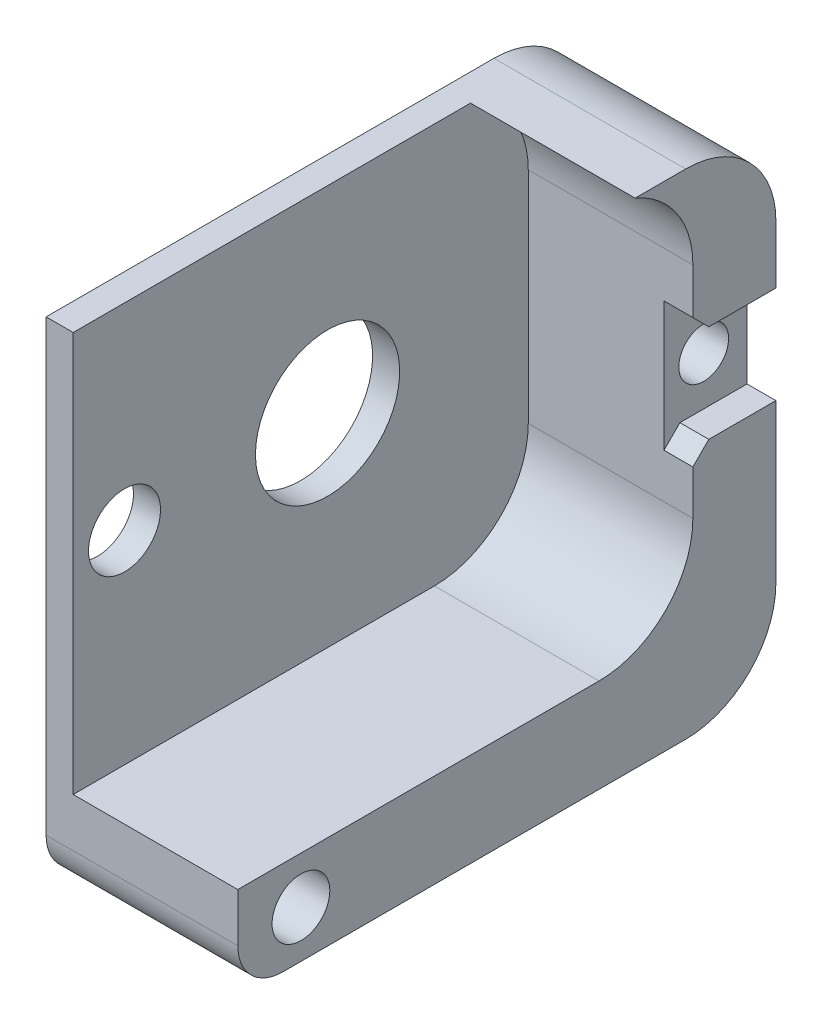
from build123d import *

# Parameters (mm, degrees)
BOSS_EXTRUDE1_START = -7.320002
SKETCH1_R           = 1.38
SKETCH1_R_2         = 1.6
BOSS_EXTRUDE1_DEPTH = 7.520002
BOSS_EXTRUDE2_START = -8.920002
SKETCH1_3_R         = 1.6
BOSS_EXTRUDE2_DEPTH = 1.6
BOSS_EXTRUDE3_START = 0.2
SKETCH1_4_R         = 1.6
SKETCH1_4_R_2       = 1.38
SKETCH1_4_R_3       = 3.995
SKETCH1_4_R_4       = 1.995
BOSS_EXTRUDE3_DEPTH = 1.5


with BuildPart() as part:
    # Sketch1 → Boss-Extrude1 (new body)
    with BuildSketch(Plane.ZY.offset(18.486711134).offset(BOSS_EXTRUDE1_START)):
        with BuildLine():
            ThreePointArc((-12.870344381, -12.708128144), (-11.997005912, -9.823687124), (-9.670344381, -7.908128144))
            Line((-9.670344381, -7.908128144), (-12.470344381, -7.908128144))
            ThreePointArc((-12.470344381, -7.908128144), (-16.005878287, -9.372594238), (-17.470344381, -12.908128144))
            Line((-17.470344381, -12.908128144), (-17.470344381, -30.276049303))
            ThreePointArc((-17.470344381, -30.276049303), (-16.005878287, -33.811583208), (-12.470344381, -35.276049303))
            Line((-12.470344381, -35.276049303), (9.844655619, -35.276049303))
            ThreePointArc((9.844655619, -35.276049303), (11.612422572, -34.543816256), (12.344655619, -32.776049303))
            Line((12.344655619, -32.776049303), (12.344655619, -30.076049303))
            Line((12.344655619, -30.076049303), (-7.670344381, -30.076049303))
            ThreePointArc((-7.670344381, -30.076049303), (-11.347299643, -28.553004565), (-12.870344381, -24.876049303))
            Line((-12.870344381, -24.876049303), (-12.870344381, -12.708128144))
        make_face()
        with Locations((-15.070344381, -18.823128144)):
            Circle(SKETCH1_R, mode=Mode.SUBTRACT)
        with Locations((8.844655619, -32.676049303)):
            Circle(SKETCH1_R_2, mode=Mode.SUBTRACT)
    extrude(amount=BOSS_EXTRUDE1_DEPTH)

    # Sketch1_3 → Boss-Extrude2 (add)
    with BuildSketch(Plane.ZY.offset(18.486711134).offset(BOSS_EXTRUDE2_START)):
        with BuildLine():
            ThreePointArc((-12.870344381, -12.708128144), (-11.997005912, -9.823687124), (-9.670344381, -7.908128144))
            Line((-9.670344381, -7.908128144), (-12.470344381, -7.908128144))
            ThreePointArc((-12.470344381, -7.908128144), (-16.005878287, -9.372594238), (-17.470344381, -12.908128144))
            Line((-17.470344381, -12.908128144), (-17.470344381, -16.123128144))
            Line((-17.470344381, -16.123128144), (-13.753187094, -16.123128144))
            Line((-13.753187094, -16.123128144), (-12.870344381, -15.240285432))
            Line((-12.870344381, -15.240285432), (-12.870344381, -12.708128144))
        make_face()
        with BuildLine():
            Line((12.344655619, -32.776049303), (12.344655619, -30.076049303))
            Line((12.344655619, -30.076049303), (-7.670344381, -30.076049303))
            ThreePointArc((-7.670344381, -30.076049303), (-11.347299643, -28.553004565), (-12.870344381, -24.876049303))
            Line((-12.870344381, -24.876049303), (-12.870344381, -22.405970857))
            Line((-12.870344381, -22.405970857), (-13.753187094, -21.523128144))
            Line((-13.753187094, -21.523128144), (-17.470344381, -21.523128144))
            Line((-17.470344381, -21.523128144), (-17.470344381, -30.276049303))
            ThreePointArc((-17.470344381, -30.276049303), (-16.005878287, -33.811583208), (-12.470344381, -35.276049303))
            Line((-12.470344381, -35.276049303), (9.844655619, -35.276049303))
            ThreePointArc((9.844655619, -35.276049303), (11.612422572, -34.543816256), (12.344655619, -32.776049303))
        make_face()
        with Locations((8.844655619, -32.676049303)):
            Circle(SKETCH1_3_R, mode=Mode.SUBTRACT)
    extrude(amount=BOSS_EXTRUDE2_DEPTH)

    # Sketch1_4 → Boss-Extrude3 (add)
    with BuildSketch(Plane.ZY.offset(18.486711134).offset(BOSS_EXTRUDE3_START)):
        with BuildLine():
            ThreePointArc((-12.870344381, -24.876049303), (-11.347299643, -28.553004565), (-7.670344381, -30.076049303))
            Line((-7.670344381, -30.076049303), (12.344655619, -30.076049303))
            Line((12.344655619, -30.076049303), (12.344655619, -32.776049303))
            ThreePointArc((12.344655619, -32.776049303), (11.612422572, -34.543816256), (9.844655619, -35.276049303))
            Line((9.844655619, -35.276049303), (-12.470344381, -35.276049303))
            ThreePointArc((-12.470344381, -35.276049303), (-16.005878287, -33.811583208), (-17.470344381, -30.276049303))
            Line((-17.470344381, -30.276049303), (-17.470344381, -21.523128144))
            Line((-17.470344381, -21.523128144), (-13.753187094, -21.523128144))
            Line((-13.753187094, -21.523128144), (-12.870344381, -22.405970857))
            Line((-12.870344381, -22.405970857), (-12.870344381, -24.876049303))
        make_face()
        with Locations((8.844655619, -32.676049303)):
            Circle(SKETCH1_4_R, mode=Mode.SUBTRACT)
        with BuildLine():
            ThreePointArc((-9.670344381, -7.908128144), (-11.997005912, -9.823687124), (-12.870344381, -12.708128144))
            Line((-12.870344381, -12.708128144), (-12.870344381, -15.240285432))
            Line((-12.870344381, -15.240285432), (-13.753187094, -16.123128144))
            Line((-13.753187094, -16.123128144), (-17.470344381, -16.123128144))
            Line((-17.470344381, -16.123128144), (-17.470344381, -12.908128144))
            ThreePointArc((-17.470344381, -12.908128144), (-16.005878287, -9.372594238), (-12.470344381, -7.908128144))
            Line((-12.470344381, -7.908128144), (-9.670344381, -7.908128144))
        make_face()
        Polygon((-12.870344381, -22.405970857), (-12.870344381, -15.240285432), (-13.753187094, -16.123128144), (-17.470344381, -16.123128144), (-17.470344381, -21.523128144), (-13.753187094, -21.523128144), align=None)
        with Locations((-15.070344381, -18.823128144)):
            Circle(SKETCH1_4_R_2, mode=Mode.SUBTRACT)
        with BuildLine():
            Line((12.344655619, -29.376049303), (12.344655619, -8.208128144))
            Line((12.344655619, -8.208128144), (-7.670344381, -8.208128144))
            ThreePointArc((-7.670344381, -8.208128144), (-10.852324897, -9.526147629), (-12.170344381, -12.708128144))
            Line((-12.170344381, -12.708128144), (-12.170344381, -24.876049303))
            ThreePointArc((-12.170344381, -24.876049303), (-10.852324897, -28.058029818), (-7.670344381, -29.376049303))
            Line((-7.670344381, -29.376049303), (12.344655619, -29.376049303))
        make_face()
        with Locations((-1.750344381, -18.823128144)):
            Circle(SKETCH1_4_R_3, mode=Mode.SUBTRACT)
        with Locations((9.499655619, -18.823128144)):
            Circle(SKETCH1_4_R_4, mode=Mode.SUBTRACT)
        with BuildLine():
            Line((12.344655619, -7.908128144), (-9.670344381, -7.908128144))
            ThreePointArc((-9.670344381, -7.908128144), (-11.997005912, -9.823687124), (-12.870344381, -12.708128144))
            Line((-12.870344381, -12.708128144), (-12.870344381, -15.240285432))
            Line((-12.870344381, -15.240285432), (-12.870344381, -22.405970857))
            Line((-12.870344381, -22.405970857), (-12.870344381, -24.876049303))
            ThreePointArc((-12.870344381, -24.876049303), (-11.347299643, -28.553004565), (-7.670344381, -30.076049303))
            Line((-7.670344381, -30.076049303), (12.344655619, -30.076049303))
            Line((12.344655619, -30.076049303), (12.344655619, -29.376049303))
            Line((12.344655619, -29.376049303), (-7.670344381, -29.376049303))
            ThreePointArc((-7.670344381, -29.376049303), (-10.852324897, -28.058029818), (-12.170344381, -24.876049303))
            Line((-12.170344381, -24.876049303), (-12.170344381, -12.708128144))
            ThreePointArc((-12.170344381, -12.708128144), (-10.852324897, -9.526147629), (-7.670344381, -8.208128144))
            Line((-7.670344381, -8.208128144), (12.344655619, -8.208128144))
            Line((12.344655619, -8.208128144), (12.344655619, -7.908128144))
        make_face()
    extrude(amount=BOSS_EXTRUDE3_DEPTH)


solid = part.part
